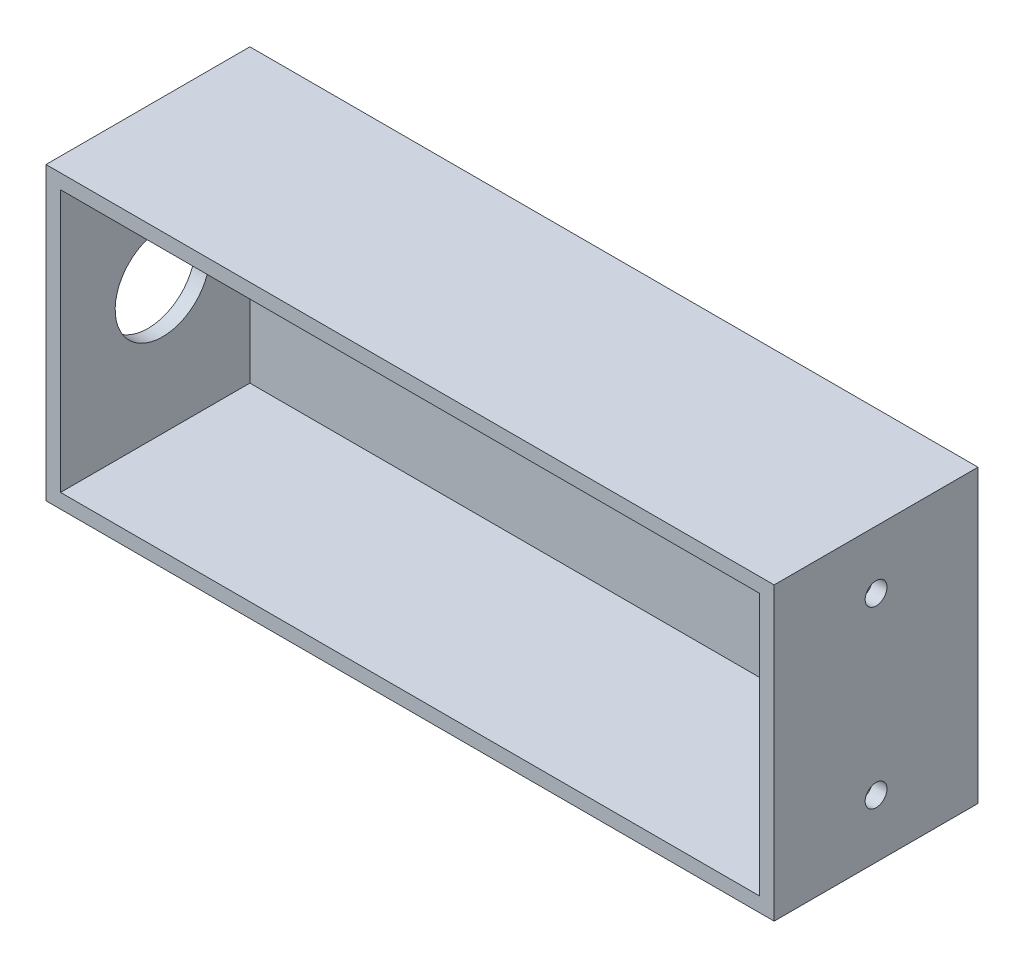
from build123d import *

# Parameters (mm, degrees)
SKETCH_2_W          = 200
SKETCH_2_H          = 80
EXTRUDE_1_DEPTH     = 56
SKETCH_3_W          = 192
SKETCH_3_H          = 72
CUT_EXTRUDE_1_DEPTH = 52
SKETCH_6_R          = 13
CUT_EXTRUDE_2_DEPTH = 4
SKETCH_8_R          = 3
CUT_EXTRUDE_3_DEPTH = 10


with BuildPart() as part:
    # 草图2 → 凸台-拉伸1 (new body)
    with BuildSketch(Plane.XY):
        Rectangle(SKETCH_2_W, SKETCH_2_H)
    extrude(amount=EXTRUDE_1_DEPTH)

    # 草图3 → 切除-拉伸1 (cut)
    with BuildSketch(Plane.XY.offset(56)):
        Rectangle(SKETCH_3_W, SKETCH_3_H)
    extrude(amount=-CUT_EXTRUDE_1_DEPTH, mode=Mode.SUBTRACT)

    # 草图6 → 切除-拉伸2 (cut)
    with BuildSketch(Plane.ZY.offset(100)):
        with Locations((28, 0)):
            Circle(SKETCH_6_R)
    extrude(amount=-CUT_EXTRUDE_2_DEPTH, mode=Mode.SUBTRACT)

    # 草图8 → 切除-拉伸3 (cut)
    with BuildSketch(Plane(origin=(100, 0, 0), x_dir=(0, 0, -1), z_dir=(1, 0, 0))):
        with Locations((-28, 24)):
            Circle(SKETCH_8_R)
        with Locations((-28, -24)):
            Circle(SKETCH_8_R)
    extrude(amount=-CUT_EXTRUDE_3_DEPTH, mode=Mode.SUBTRACT)


solid = part.part
